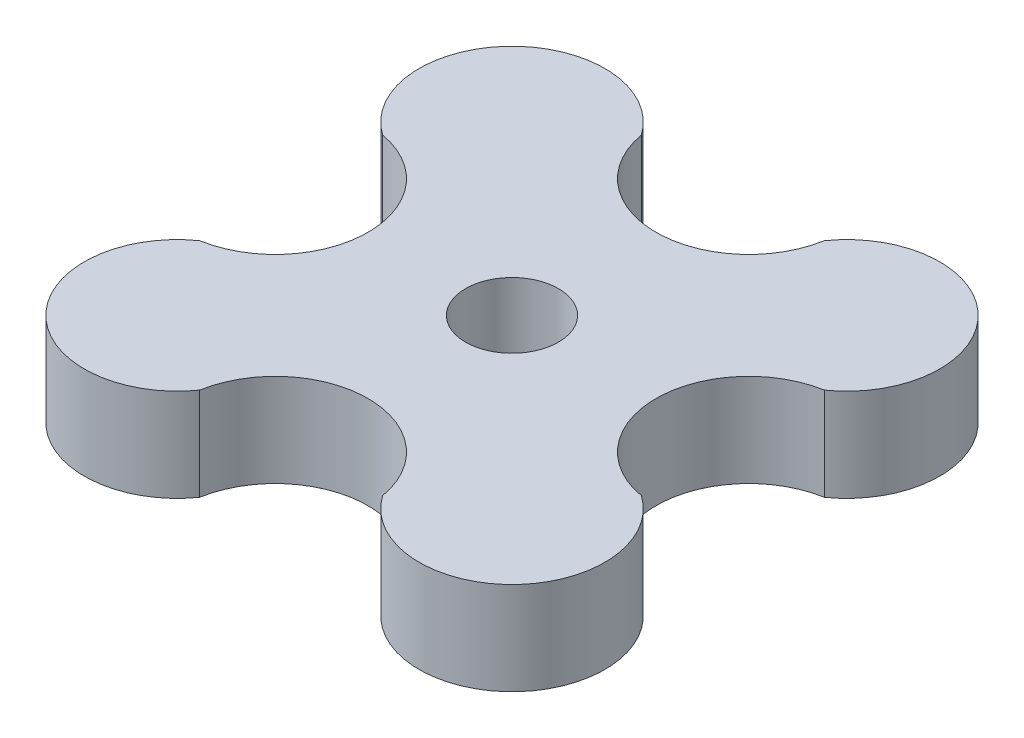
from build123d import *

# Parameters (mm, degrees)
BOSS_EXTRUDE1_DEPTH = 5
SKETCH2_R           = 2.5
CUT_EXTRUDE1_DEPTH  = 5


with BuildPart() as part:
    # Sketch1 → Boss-Extrude1 (new body)
    with BuildSketch(Plane(origin=(0, 0, 0), x_dir=(1, 0, 0), z_dir=(0, 1, 0))):
        with BuildLine():
            ThreePointArc((11.892024371, 4.925837778), (12.551145366, 12.551145366), (4.925837778, 11.892024371))
            ThreePointArc((4.925837778, 11.892024371), (0, 7.75), (-4.925837778, 11.892024371))
            ThreePointArc((-4.925837778, 11.892024371), (-12.551145366, 12.551145366), (-11.892024371, 4.925837778))
            ThreePointArc((-11.892024371, 4.925837778), (-7.75, 0), (-11.892024371, -4.925837778))
            ThreePointArc((-11.892024371, -4.925837778), (-12.551145366, -12.551145366), (-4.925837778, -11.892024371))
            ThreePointArc((-4.925837778, -11.892024371), (0, -7.75), (4.925837778, -11.892024371))
            ThreePointArc((4.925837778, -11.892024371), (12.551145366, -12.551145366), (11.892024371, -4.925837778))
            ThreePointArc((11.892024371, -4.925837778), (7.75, 0), (11.892024371, 4.925837778))
        make_face()
    extrude(amount=BOSS_EXTRUDE1_DEPTH)

    # Sketch2 → Cut-Extrude1 (cut)
    with BuildSketch(Plane(origin=(0, 5, 0), x_dir=(1, 0, 0), z_dir=(0, 1, 0))):
        Circle(SKETCH2_R)
    extrude(amount=-CUT_EXTRUDE1_DEPTH, mode=Mode.SUBTRACT)


solid = part.part
